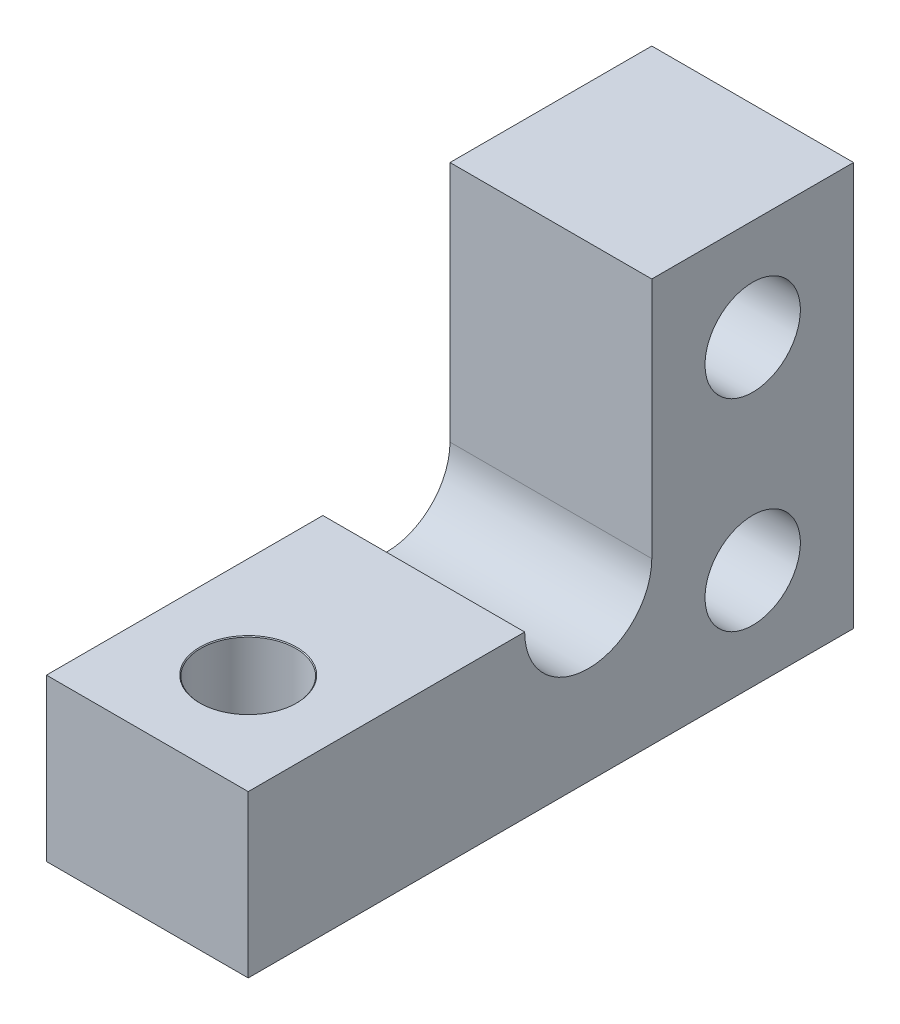
from build123d import *

# Parameters (mm, degrees)
BOSS_EXTRUDE1_DEPTH             = 6.35
F_3_0MM_DOWEL_HOLE1_D           = 3
F_3_0MM_DOWEL_HOLE1_CSINK_D     = 3.05
F_3_0MM_DOWEL_HOLE1_CSINK_ANGLE = 90
F_3_0MM_DOWEL_HOLE2_D           = 3
F_3_0MM_DOWEL_HOLE2_CSINK_D     = 3.05
F_3_0MM_DOWEL_HOLE2_CSINK_ANGLE = 90


with BuildPart() as part:
    # Sketch1 → Boss-Extrude1 (new body)
    with BuildSketch(Plane(origin=(0, 0, 0), x_dir=(0, 0, -1), z_dir=(1, 0, 0))):
        with BuildLine():
            Line((-19.05, 0), (0, 0))
            Line((0, 0), (0, 12.7))
            Line((0, 12.7), (-6.35, 12.7))
            Line((-6.35, 12.7), (-6.35, 5.08))
            ThreePointArc((-6.35, 5.08), (-8.35, 3.08), (-10.35, 5.08))
            Line((-10.35, 5.08), (-19.05, 5.08))
            Line((-19.05, 5.08), (-19.05, 0))
        make_face()
    extrude(amount=BOSS_EXTRUDE1_DEPTH)

    # Ø3.0mm Dowel Hole1 (through all)
    with Locations(Plane.ZY):
        with Locations((3.175, 3.175), (3.175, 9.525)):
            CounterSinkHole(F_3_0MM_DOWEL_HOLE1_D / 2, F_3_0MM_DOWEL_HOLE1_CSINK_D / 2, counter_sink_angle=F_3_0MM_DOWEL_HOLE1_CSINK_ANGLE)

    # Ø3.0mm Dowel Hole2 (through all)
    with Locations(Plane(origin=(0, 5.08, 0), x_dir=(1, 0, 0), z_dir=(0, 1, 0))):
        with Locations((3.175, -15.875)):
            CounterSinkHole(F_3_0MM_DOWEL_HOLE2_D / 2, F_3_0MM_DOWEL_HOLE2_CSINK_D / 2, counter_sink_angle=F_3_0MM_DOWEL_HOLE2_CSINK_ANGLE)


solid = part.part
